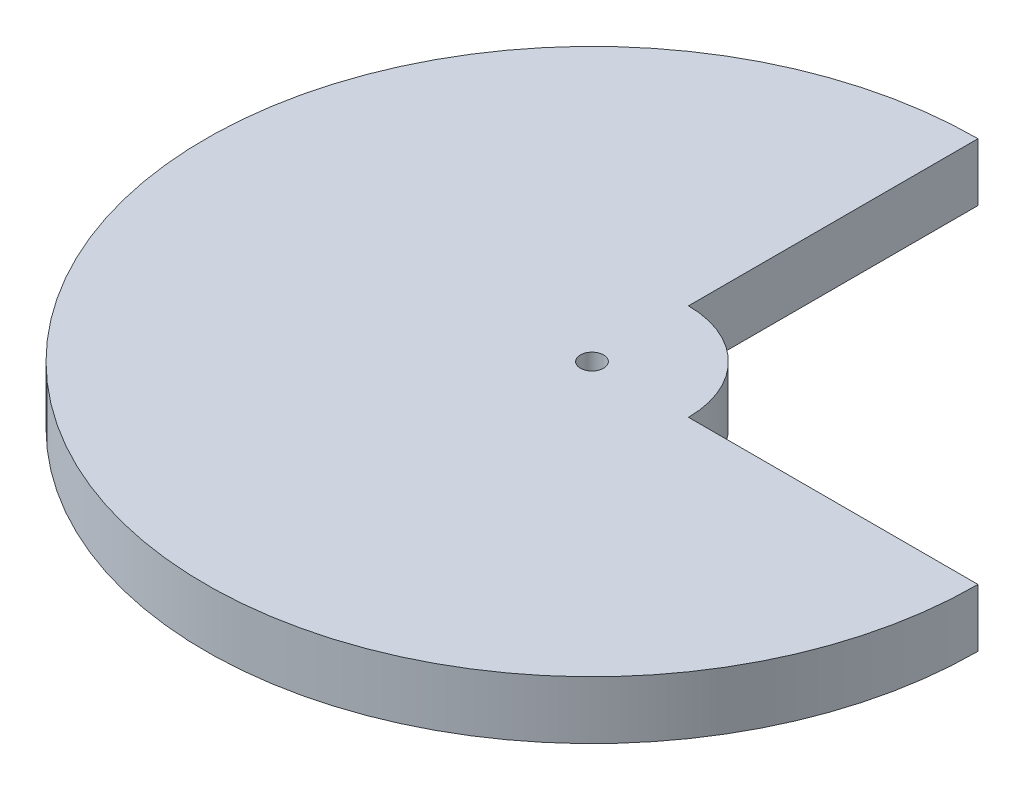
from build123d import *

# Parameters (mm, degrees)
SKETCH_1_R      = 0.6
EXTRUDE_1_DEPTH = 3


with BuildPart() as part:
    # 草图1 → 凸台-拉伸1 (new body)
    with BuildSketch(Plane(origin=(0, 0, 0), x_dir=(1, 0, 0), z_dir=(0, 1, 0))):
        with BuildLine():
            Line((0, 5), (0, 20))
            ThreePointArc((0, 20), (-14.142135624, -14.142135624), (20, 0))
            Line((20, 0), (5, 0))
            ThreePointArc((5, 0), (3.535533906, 3.535533906), (0, 5))
        make_face()
        Circle(SKETCH_1_R, mode=Mode.SUBTRACT)
    extrude(amount=EXTRUDE_1_DEPTH)


solid = part.part
